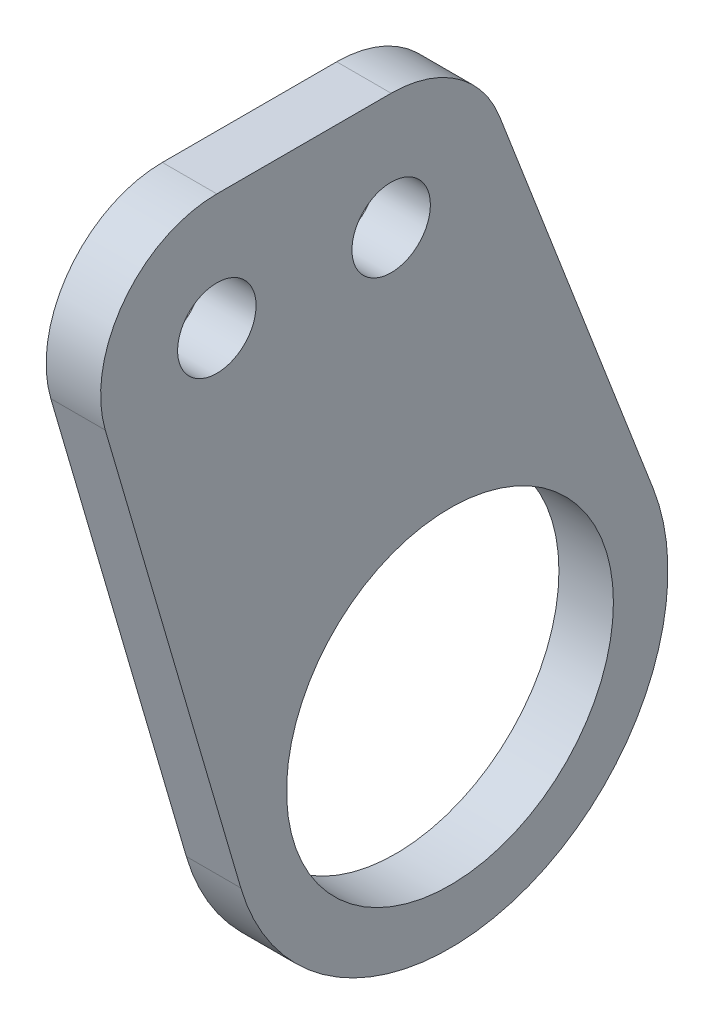
from build123d import *

# Parameters (mm, degrees)
SKETCH1_R           = 14.2875
SKETCH1_R_2         = 3.429
BOSS_EXTRUDE1_DEPTH = 4.7625


with BuildPart() as part:
    # Sketch1 → Boss-Extrude1 (new body)
    with BuildSketch(Plane(origin=(0, 0, 0), x_dir=(0, 0, -1), z_dir=(1, 0, 0))):
        with BuildLine():
            Line((-20.3835, 48.26), (-5.1435, 48.26))
            ThreePointArc((-5.1435, 48.26), (0.606928002, 46.476047862), (4.337968538, 41.750664919))
            Line((4.337968538, 41.750664919), (17.77775351, 6.844996724))
            ThreePointArc((17.77775351, 6.844996724), (6.097008594, -18.047963492), (-18.286717832, -5.33839404))
            Line((-18.286717832, -5.33839404), (-30.136416177, 35.252856512))
            ThreePointArc((-30.136416177, 35.252856512), (-28.512232307, 44.195023468), (-20.3835, 48.26))
        make_face()
        Circle(SKETCH1_R, mode=Mode.SUBTRACT)
        with Locations((-20.3835, 38.1)):
            Circle(SKETCH1_R_2, mode=Mode.SUBTRACT)
        with Locations((-5.1435, 38.1)):
            Circle(SKETCH1_R_2, mode=Mode.SUBTRACT)
    extrude(amount=BOSS_EXTRUDE1_DEPTH)


solid = part.part
